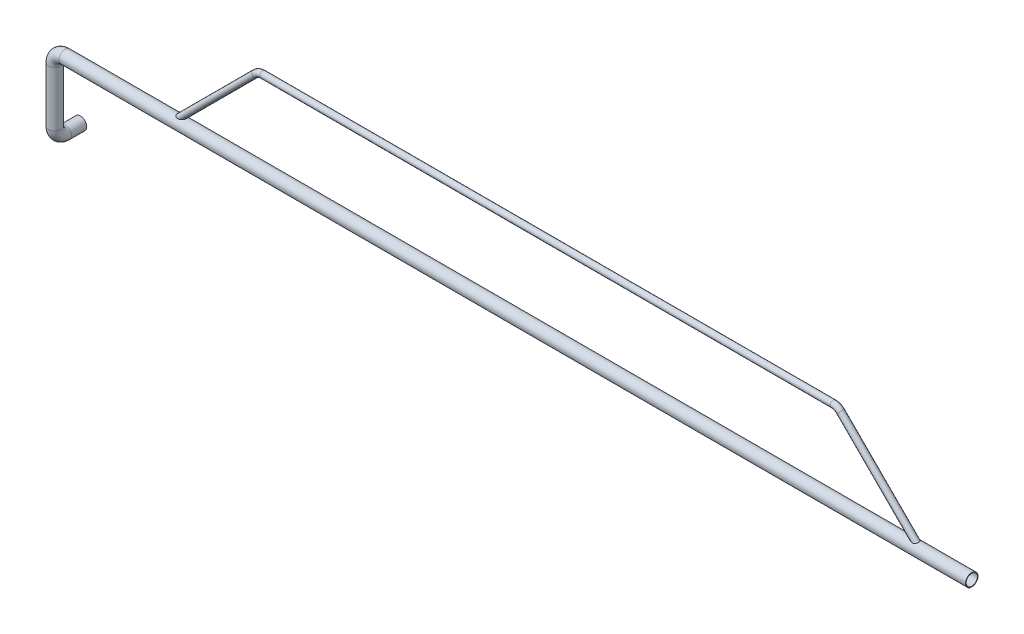
from build123d import *

# Parameters (mm, degrees)
SWEEP_THIN1_PROFILE_R   = 30
SWEEP_THIN1_PROFILE_R_2 = 27
SWEEP_THIN2_PROFILE_R   = 15
SWEEP_THIN2_PROFILE_R_2 = 12


with BuildPart() as part:
    # Sweep-Thin1: sweep along a curve in space
    with BuildLine() as sweep_thin1_path:
        Line((-24893.006183482, -8356.204513264, 38950.249256715), (-29246.554683292, -8356.204513264, 38950.249256715))
        ThreePointArc((-29296.554683292, -8406.204513264, 38950.249256715), (-29281.910022351, -8370.849174205, 38950.249256715), (-29246.554683292, -8356.204513264, 38950.249256715))
        Line((-29296.554683292, -8406.204513264, 38950.249256715), (-29296.554683292, -8670.518633414, 38950.249256715))
        ThreePointArc((-29296.554683292, -8720.518633414, 38900.249256715), (-29296.554683292, -8705.873972473, 38935.604595774), (-29296.554683292, -8670.518633414, 38950.249256715))
        Line((-29296.554683292, -8720.518633414, 38900.249256715), (-29296.554683292, -8720.518633414, 38826.890196057))
    # Sweep-Thin1 profile (on start of the path) → Sweep-Thin1 (sweep)
    with BuildSketch(Plane(origin=(-24893.006183482, -8356.204513264, 38950.249256715), x_dir=(0, 0, -1), z_dir=(-1, 0, 0))):
        Circle(SWEEP_THIN1_PROFILE_R)
        Circle(SWEEP_THIN1_PROFILE_R_2, mode=Mode.SUBTRACT)
    sweep(path=sweep_thin1_path.line)


with BuildPart() as body_2:
    # Sweep-Thin2: sweep along a curve in space
    with BuildLine() as sweep_thin2_path:
        Line((-25137.374453509, -8356.204513264, 38950.249256715), (-25522.729792568, -7970.849174205, 38950.249256715))
        ThreePointArc((-25558.085131628, -7956.204513264, 38950.249256715), (-25538.950960009, -7960.010536639, 38950.249256715), (-25522.729792568, -7970.849174205, 38950.249256715))
        Line((-25558.085131628, -7956.204513264, 38950.249256715), (-28297.486918384, -7956.204513264, 38950.249256715))
        ThreePointArc((-28297.486918384, -7956.204513264, 38950.249256715), (-28316.621090003, -7960.010536639, 38950.249256715), (-28332.842257444, -7970.849174205, 38950.249256715))
        Line((-28332.842257444, -7970.849174205, 38950.249256715), (-28718.197596503, -8356.204513264, 38950.249256715))
    # Sweep-Thin2 profile (on start of the path) → Sweep-Thin2 (sweep)
    with BuildSketch(Plane(origin=(-25137.374453509, -8356.204513264, 38950.249256715), x_dir=(0.7071067811865483, 0.7071067811865467, 0), z_dir=(-0.7071067811865467, 0.7071067811865483, 0))):
        Circle(SWEEP_THIN2_PROFILE_R)
        Circle(SWEEP_THIN2_PROFILE_R_2, mode=Mode.SUBTRACT)
    sweep(path=sweep_thin2_path.line)


solid = Compound([part.part, body_2.part])
